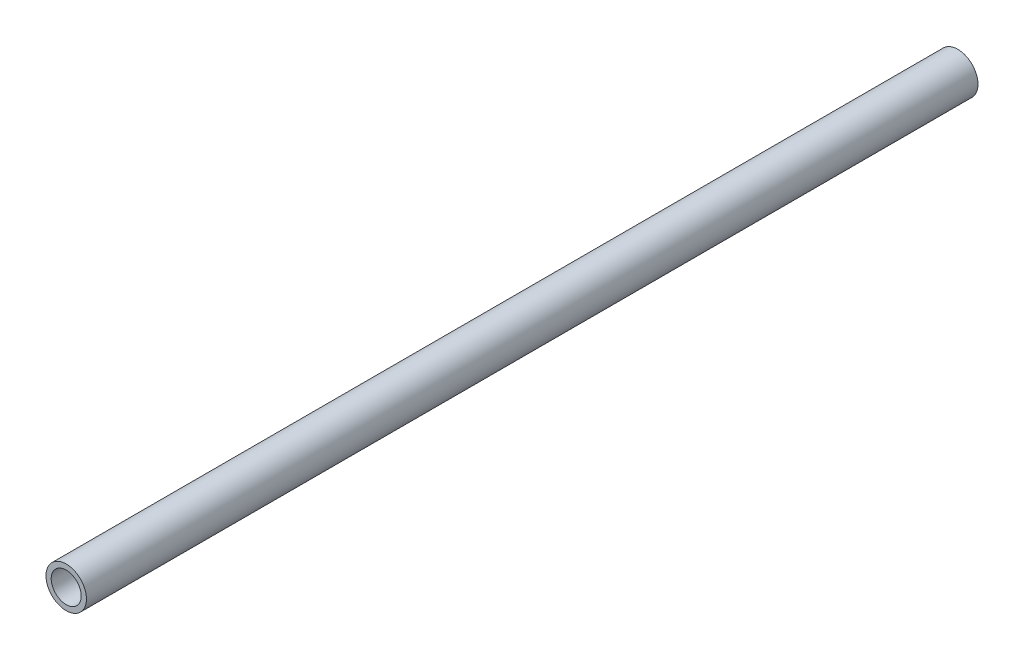
from build123d import *

# Parameters (mm, degrees)
SKETCH1_R           = 10.668
SKETCH1_R_2         = 7.8994
EXTRUDE_THIN1_DEPTH = 235


with BuildPart() as part:
    # Sketch1 → Extrude-Thin1 (new body, symmetric)
    with BuildSketch(Plane.XY):
        Circle(SKETCH1_R)
        Circle(SKETCH1_R_2, mode=Mode.SUBTRACT)
    extrude(amount=EXTRUDE_THIN1_DEPTH, both=True)


solid = part.part
